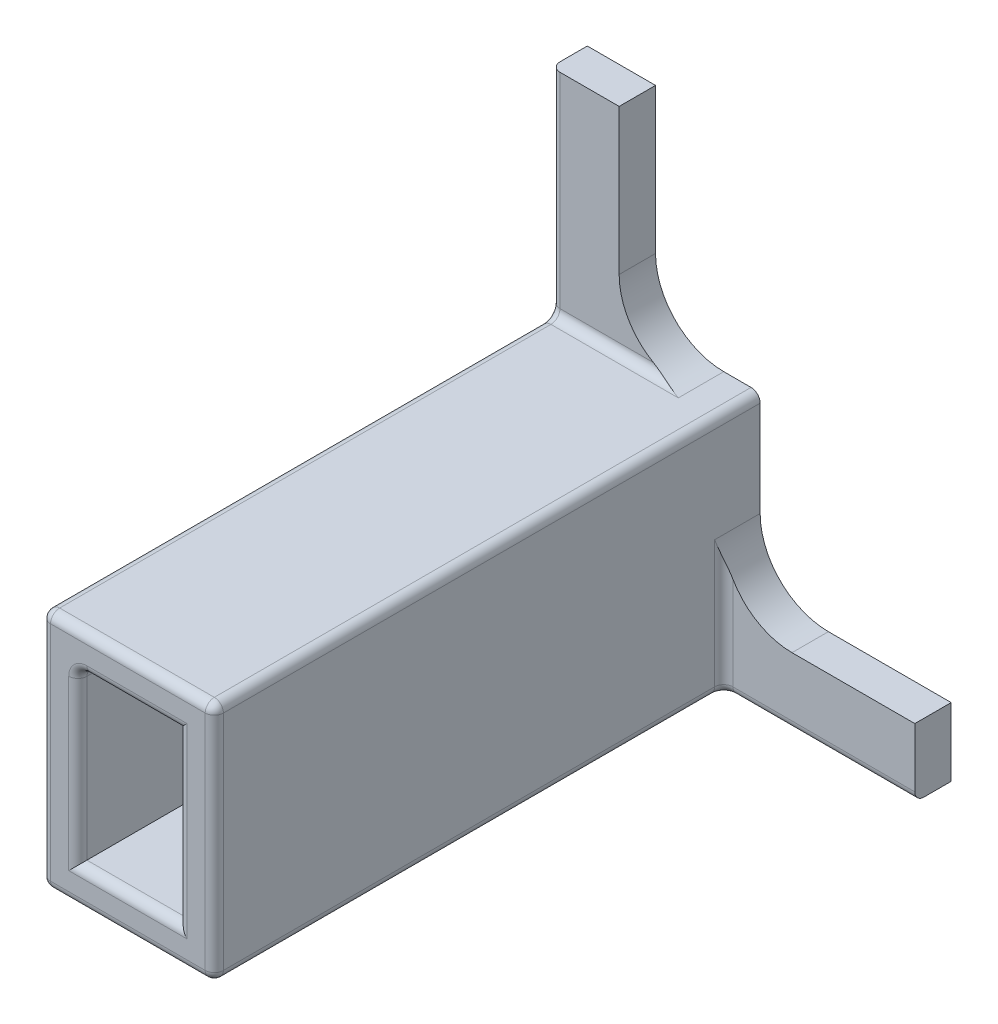
from build123d import *

# Parameters (mm, degrees)
SZKIC1_W                    = 22
SZKIC1_H                    = 37
DODANIE_WYCI_GNI_CIE1_DEPTH = 120
SZKIC2_W                    = 42
SZKIC2_H                    = 15
SZKIC2_W_2                  = 15
SZKIC2_H_2                  = 47
WYTNIJ_WYCI_GNI_CIE1_DEPTH  = 112
ZAOKR_GLENIE1_R             = 15
ZAOKR_GLENIE2_R             = 2


with BuildPart() as part:
    # Szkic1 → Dodanie-wyciągnięcie1 (new body)
    with BuildSketch(Plane.XY):
        Polygon((0, 0), (0, 100), (15, 100), (15, 53), (38, 53), (38, 15), (80, 15), (80, 0), align=None)
        with Locations((19, 26.5)):
            Rectangle(SZKIC1_W, SZKIC1_H, mode=Mode.SUBTRACT)
    extrude(amount=DODANIE_WYCI_GNI_CIE1_DEPTH)

    # Szkic2 → Wytnij-wyciągnięcie1 (cut)
    with BuildSketch(Plane.XY.offset(120)):
        with Locations((59, 7.5)):
            Rectangle(SZKIC2_W, SZKIC2_H)
        with Locations((7.5, 76.5)):
            Rectangle(SZKIC2_W_2, SZKIC2_H_2)
    extrude(amount=-WYTNIJ_WYCI_GNI_CIE1_DEPTH, mode=Mode.SUBTRACT)

    # Zaokrąglenie1
    zaokr_glenie1_edges = [part.edges().sort_by_distance(p)[0] for p in [
        (38, 15, 4),
        (15, 53, 4),
    ]]
    fillet(zaokr_glenie1_edges, radius=ZAOKR_GLENIE1_R)

    # Zaokrąglenie2
    zaokr_glenie2_edges = [part.edges().sort_by_distance(p)[0] for p in [
        (38, 26.5, 120),
        (0, 0, 60),
        (38, 53, 60),
        (19, 53, 120),
        (8, 45, 60),
        (8, 26.5, 120),
        (19, 8, 120),
        (30, 26.5, 120),
        (19, 45, 120),
        (19, 0, 120),
        (38, 22.5, 8),
        (38, 0, 64),
        (59, 0, 8),
        (0, 26.5, 120),
        (0, 76.5, 8),
        (0, 53, 64),
        (22.5, 53, 8),
    ]]
    fillet(zaokr_glenie2_edges, radius=ZAOKR_GLENIE2_R)


solid = part.part
